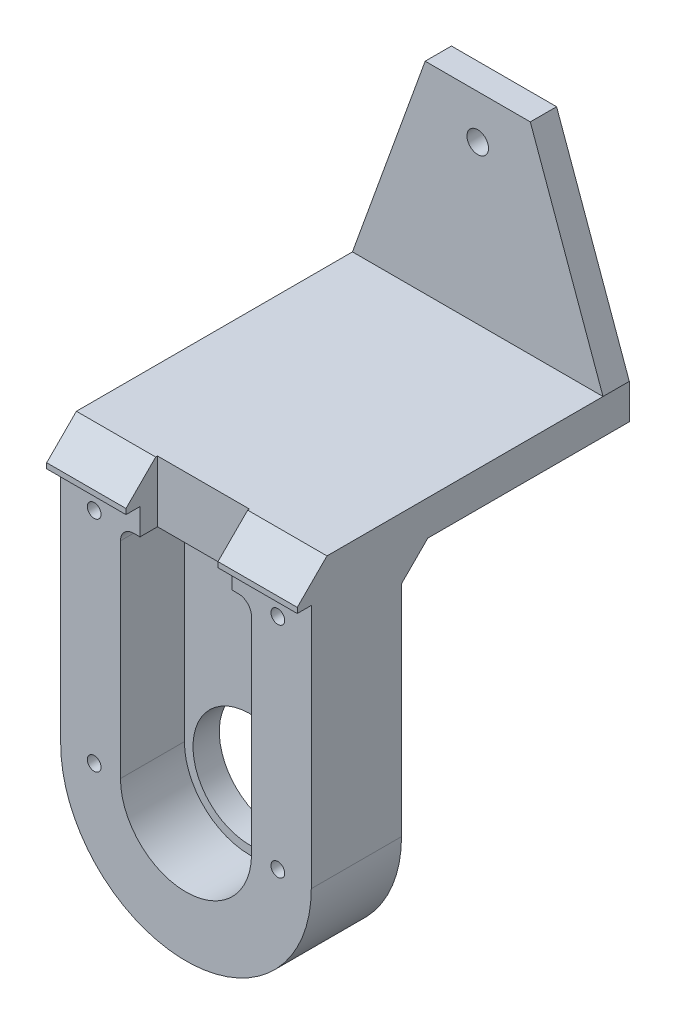
from build123d import *

# Parameters (mm, degrees)
MODEL_R             = 0.7834936
EXTRUDE_1_DEPTH     = 10.3
MODEL_3_W           = 10.5
MODEL_3_H           = 3
EXTRUDE_2_DEPTH     = 8.3
MODEL_4_R           = 6.5
EXTRUDE_3_DEPTH     = 3
SKETCH_2_W          = 28.6
SKETCH_2_H          = 4
EXTRUDE_4_DEPTH     = 1.6
SKETCH_3_W          = 10.5
SKETCH_3_H          = 5.089019843
CUT_EXTRUDE_1_DEPTH = 5.6
MODEL_5_W           = 28.6
MODEL_5_H           = 4
EXTRUDE_5_DEPTH     = 26
MODEL_6_R           = 0.7834936
EXTRUDE_6_DEPTH     = 3
SKETCH_4_R          = 1.229367
EXTRUDE_7_DEPTH     = 3
SKETCH_4_3_R        = 1.229367
CUT_EXTRUDE_2_DEPTH = 8
CHAMFER_1_SIZE      = 3
CUT_EXTRUDE_3_DEPTH = 30


with BuildPart() as part:
    # Model → Extrude 1 (new body)
    with BuildSketch(Plane.XY):
        with BuildLine():
            Line((-37.212112801, 31.669809042), (-37.212112801, -0.330212606))
            ThreePointArc((-37.212112801, -0.330212606), (-22.912101977, -14.630201782), (-8.612112801, -0.330190958))
            Line((-8.612112801, -0.330190958), (-8.612112801, 31.669809042))
            Line((-8.612112801, 31.669809042), (-37.212112801, 31.669809042))
        make_face()
        with BuildLine():
            Line((-28.162112801, 27.669809042), (-17.662112801, 27.669809042))
            Line((-17.662112801, 27.669809042), (-17.662112801, 24.669809042))
            Line((-17.662112801, 24.669809042), (-16.932112801, 24.669809042))
            ThreePointArc((-16.932112801, 24.669809042), (-15.87145263, 24.230469214), (-15.432112801, 23.169809042))
            Line((-15.432112801, 23.169809042), (-15.432112801, -0.330190958))
            ThreePointArc((-15.432112801, -0.330190958), (-22.912112801, -7.810190958), (-30.392112801, -0.330190958))
            Line((-30.392112801, -0.330190958), (-30.392112801, 23.169809042))
            ThreePointArc((-30.392112801, 23.169809042), (-29.952772973, 24.230469214), (-28.892112801, 24.669809042))
            Line((-28.892112801, 24.669809042), (-28.162112801, 24.669809042))
            Line((-28.162112801, 24.669809042), (-28.162112801, 27.669809042))
        make_face(mode=Mode.SUBTRACT)
        with Locations((-33.392112801, 24.669809042)):
            Circle(MODEL_R, mode=Mode.SUBTRACT)
        with Locations((-12.432112801, 24.669809042)):
            Circle(MODEL_R, mode=Mode.SUBTRACT)
        with Locations((-33.392112801, -0.330190958)):
            Circle(MODEL_R, mode=Mode.SUBTRACT)
        with Locations((-12.432112801, -0.330190958)):
            Circle(MODEL_R, mode=Mode.SUBTRACT)
    extrude(amount=EXTRUDE_1_DEPTH)

    # Model_3 → Extrude 2 (add)
    with BuildSketch(Plane.XY):
        with Locations((-22.912112801, 26.169809042)):
            Rectangle(MODEL_3_W, MODEL_3_H)
    extrude(amount=EXTRUDE_2_DEPTH)

    # Model_4 → Extrude 3 (add)
    with BuildSketch(Plane.XY):
        with BuildLine():
            Line((-17.662112801, 24.669809042), (-28.162112801, 24.669809042))
            Line((-28.162112801, 24.669809042), (-28.892112801, 24.669809042))
            ThreePointArc((-28.892112801, 24.669809042), (-29.952772973, 24.230469214), (-30.392112801, 23.169809042))
            Line((-30.392112801, 23.169809042), (-30.392112801, -0.330190958))
            ThreePointArc((-30.392112801, -0.330190958), (-22.912112801, -7.810190958), (-15.432112801, -0.330190958))
            Line((-15.432112801, -0.330190958), (-15.432112801, 23.169809042))
            ThreePointArc((-15.432112801, 23.169809042), (-15.87145263, 24.230469214), (-16.932112801, 24.669809042))
            Line((-16.932112801, 24.669809042), (-17.662112801, 24.669809042))
        make_face()
        with Locations((-22.912112801, -0.330190958)):
            Circle(MODEL_4_R, mode=Mode.SUBTRACT)
    extrude(amount=EXTRUDE_3_DEPTH)

    # Sketch 2 → Extrude 4 (add)
    with BuildSketch(Plane.XY.offset(10.3)):
        with Locations((-22.912112801, 29.669809042)):
            Rectangle(SKETCH_2_W, SKETCH_2_H)
    extrude(amount=EXTRUDE_4_DEPTH)

    # Sketch 3 → Cut-Extrude 1 (cut)
    with BuildSketch(Plane.XZ.offset(-27.669809042)):
        with Locations((-22.912112801, 10.844509922)):
            Rectangle(SKETCH_3_W, SKETCH_3_H)
    extrude(amount=-CUT_EXTRUDE_1_DEPTH, mode=Mode.SUBTRACT)

    # Model_5 → Extrude 5 (add)
    with BuildSketch(Plane.XY):
        with Locations((-22.912112801, 29.669809042)):
            Rectangle(MODEL_5_W, MODEL_5_H)
    extrude(amount=-EXTRUDE_5_DEPTH)

    # Model_6 → Extrude 6 (add)
    with BuildSketch(Plane.XY):
        with Locations((-12.432112801, -0.330190958)):
            Circle(MODEL_6_R)
        with Locations((-33.392112801, -0.330190958)):
            Circle(MODEL_6_R)
        with Locations((-12.432112801, 24.669809042)):
            Circle(MODEL_6_R)
        with Locations((-33.392112801, 24.669809042)):
            Circle(MODEL_6_R)
    extrude(amount=EXTRUDE_6_DEPTH)

    # Sketch 4 → Extrude 7 (add)
    with BuildSketch(Plane(origin=(0, 0, -26), x_dir=(-1, 0, 0), z_dir=(0, 0, -1))):
        Polygon((37.212112801, 31.669809042), (28.912112801, 54.669809042), (16.912112801, 54.669809042), (8.612112801, 31.669809042), align=None)
        with Locations((22.912112801, 49.669809042)):
            Circle(SKETCH_4_R, mode=Mode.SUBTRACT)
    extrude(amount=-EXTRUDE_7_DEPTH)

    # Sketch 4_3 → Cut-Extrude 2 (cut)
    with BuildSketch(Plane(origin=(0, 0, -26), x_dir=(-1, 0, 0), z_dir=(0, 0, -1))):
        with Locations((12.612112801, 29.669809042)):
            Circle(SKETCH_4_3_R)
        with Locations((33.212112801, 29.669809042)):
            Circle(SKETCH_4_3_R)
        with Locations((22.912112801, 29.669809042)):
            Circle(SKETCH_4_3_R)
    extrude(amount=-CUT_EXTRUDE_2_DEPTH, mode=Mode.SUBTRACT)

    # Chamfer 1
    chamfer_1_edges = [part.edges().sort_by_distance(p)[0] for p in [
        (-22.912112801, 27.669809042, 0),
    ]]
    chamfer(chamfer_1_edges, length=CHAMFER_1_SIZE)

    # Sketch 5 → Cut-Extrude 3 (cut)
    with BuildSketch(Plane(origin=(-8.612112801, 0, 0), x_dir=(0, 0, -1), z_dir=(1, 0, 0))):
        Polygon((-11.9, 31.669809042), (-11.9, 28.278558322), (-8.50874928, 31.669809042), align=None)
    extrude(amount=-CUT_EXTRUDE_3_DEPTH, mode=Mode.SUBTRACT)


solid = part.part
